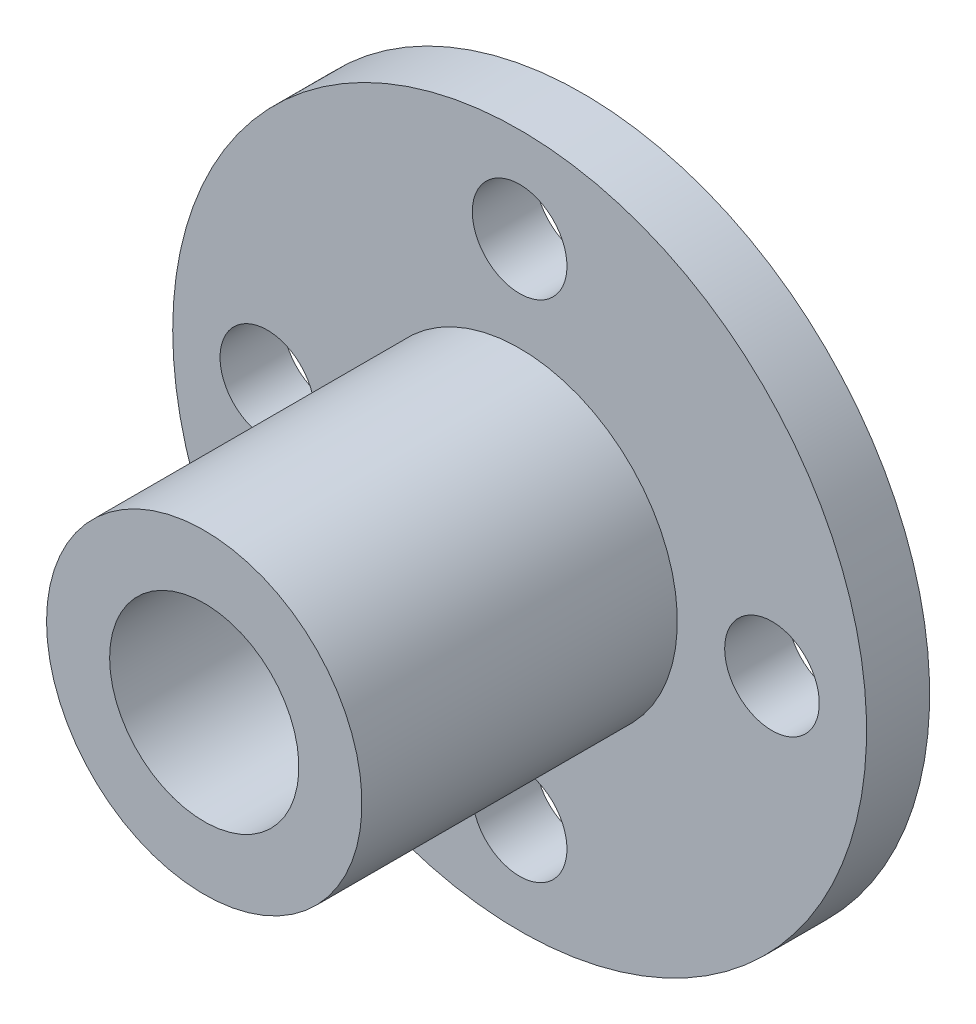
from build123d import *

# Parameters (mm, degrees)
SKETCH_2_R          = 1.5
SKETCH_2_R_2        = 3
CUT_EXTRUDE_1_DEPTH = 25


with BuildPart() as part:
    # 草图1 → 旋转1 (revolve)
    with BuildSketch(Plane(origin=(0, 0, 0), x_dir=(1, 0, 0), z_dir=(0, 1, 0))):
        Polygon((0, 0), (5, 0), (5, 10), (11, 10), (11, 12), (0, 12), align=None)
    revolve(axis=Axis((0, 0, -12), (0, 0, 1)))

    # 草图2 → 切除-拉伸1 (cut)
    with BuildSketch(Plane(origin=(0, 0, -12), x_dir=(-1, 0, 0), z_dir=(0, 0, -1))):
        with Locations((8, 0)):
            Circle(SKETCH_2_R)
        Circle(SKETCH_2_R_2)
        with Locations((0, -8)):
            Circle(SKETCH_2_R)
        with Locations((-8, 0)):
            Circle(SKETCH_2_R)
        with Locations((0, 8)):
            Circle(SKETCH_2_R)
    extrude(amount=-CUT_EXTRUDE_1_DEPTH, mode=Mode.SUBTRACT)


solid = part.part
